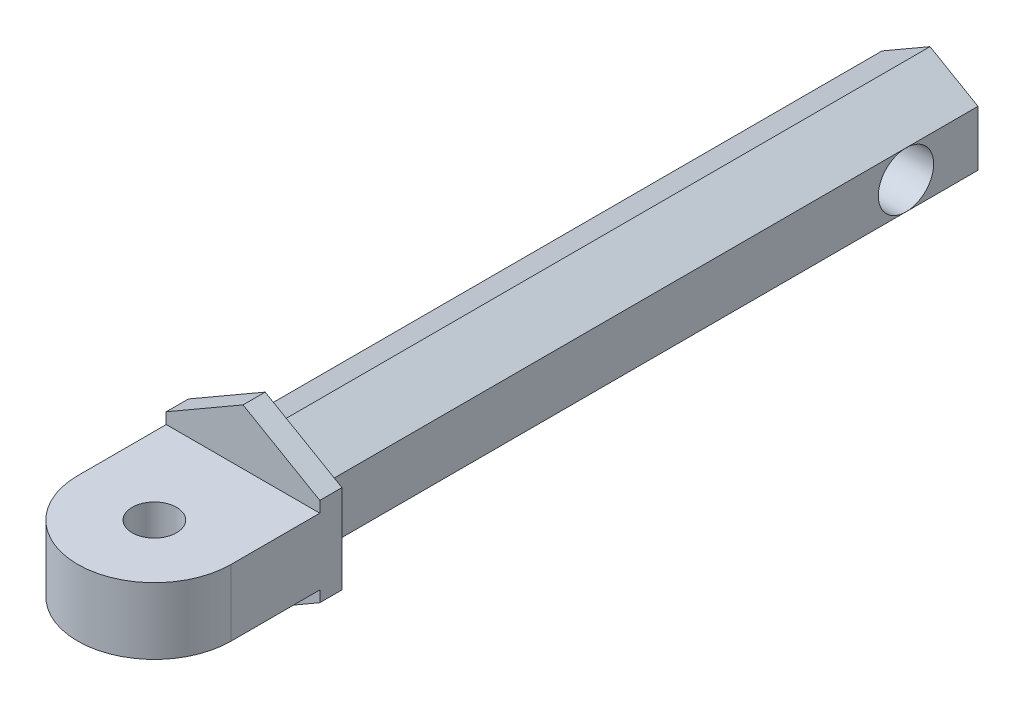
from build123d import *

# Parameters (mm, degrees)
EXTRUDE_1_DEPTH      = 1
SKETCH_2_R           = 1
EXTRUDE_3_DEPTH      = 1.5
EXTRUDE_3_DEPTH_BACK = 1.5
EXTRUDE_4_DEPTH      = 30
SKETCH_4_R           = 1.25
CUT_EXTRUDE_1_DEPTH  = 4.330127


with BuildPart() as part:
    # Sketch 1 → Extrude 1 (new body)
    with BuildSketch(Plane.XY):
        Polygon((0, 4), (-3.464101615, 2), (-3.464101615, -2), (0, -4), (3.464101615, -2), (3.464101615, 2), align=None)
    extrude(amount=EXTRUDE_1_DEPTH)

    # Sketch 2 → Extrude 3 (add, two sides)
    with BuildSketch(Plane(origin=(0, 0, 0), x_dir=(1, 0, 0), z_dir=(0, 1, 0))) as extrude_3_sk:
        with BuildLine():
            Line((-3.464101615, -1), (3.464101615, -1))
            Line((3.464101615, -1), (3.464101615, -5))
            ThreePointArc((3.464101615, -5), (0, -8.464101615), (-3.464101615, -5))
            Line((-3.464101615, -5), (-3.464101615, -1))
        make_face()
        with Locations((0, -5)):
            Circle(SKETCH_2_R, mode=Mode.SUBTRACT)
    extrude(amount=EXTRUDE_3_DEPTH)
    extrude(extrude_3_sk.sketch, amount=-EXTRUDE_3_DEPTH_BACK)

    # Sketch 3 → Extrude 4 (add)
    with BuildSketch(Plane(origin=(0, 0, 0), x_dir=(-1, 0, 0), z_dir=(0, 0, -1))):
        Polygon((0, 2.5), (-2.165063509, 1.25), (-2.165063509, -1.25), (0, -2.5), (2.165063509, -1.25), (2.165063509, 1.25), align=None)
    extrude(amount=EXTRUDE_4_DEPTH)

    # Sketch 4 → Cut-Extrude 1 (cut)
    with BuildSketch(Plane.ZY.offset(2.165063509)):
        with Locations((-26.75, 0)):
            Circle(SKETCH_4_R)
    extrude(amount=-CUT_EXTRUDE_1_DEPTH, mode=Mode.SUBTRACT)


solid = part.part
